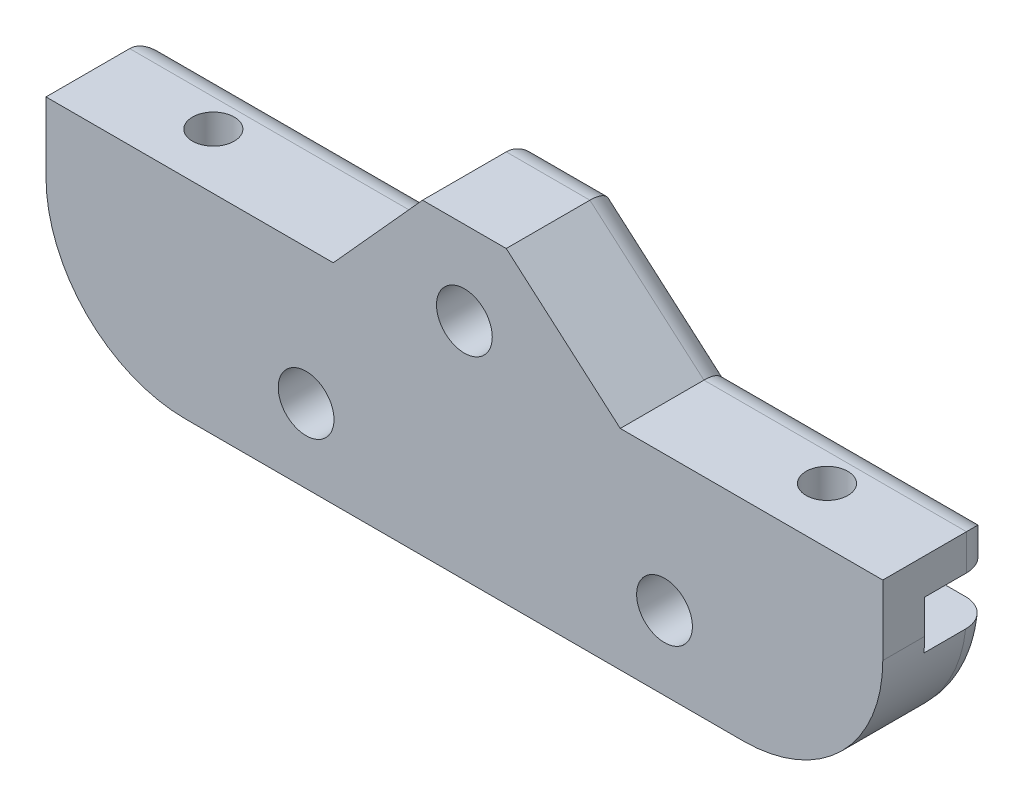
from build123d import *

# Parameters (mm, degrees)
BOSS_EXTRU_1_DEPTH             = 4
BOSS_EXTRU_1_DEPTH_BACK        = 4
ESQUISSE3_R                    = 2
ENL_V_MAT_EXTRU_1_DEPTH        = 5
ENL_V_MAT_EXTRU_1_DEPTH_BACK   = 5
BOSS_EXTRU_2_REACH             = 6
BOSS_EXTRU_2_DIRECTION_2_REACH = 6
ENL_V_START                    = -4
ESQUISSE4_W                    = 60
ESQUISSE4_H                    = 3.5
ENL_V_MAT_EXTRU_2_DEPTH        = 5
ENL_V_START_2                  = 9.713229
ESQUISSE7_R                    = 1.5
ENL_V_MAT_EXTRU_4_DEPTH        = 6.063229
CONG_1_R                       = 10
CONG_2_R                       = 2


with BuildPart() as part:
    # Esquisse1 → Boss.-Extru.1 (new body, two sides)
    with BuildSketch(Plane.XY) as boss_extru_1_sk:
        Polygon((-18.056919343, 0.131274222), (-15.479170984, -5.286770941), (18.771312817, -5.286770941), (21.159805355, 1.060426821), (3, 16.8), (-3, 16.8), align=None)
    extrude(amount=BOSS_EXTRU_1_DEPTH)
    extrude(boss_extru_1_sk.sketch, amount=-BOSS_EXTRU_1_DEPTH_BACK)

    # Esquisse3 → Enl_v. mat.-Extru.1 (cut, two sides)
    with BuildSketch(Plane.XY) as enl_v_mat_extru_1_sk:
        with Locations((0, 10.8)):
            Circle(ESQUISSE3_R)
        with Locations((-11.35, 0)):
            Circle(ESQUISSE3_R)
        with Locations((14.35, 0)):
            Circle(ESQUISSE3_R)
    extrude(amount=ENL_V_MAT_EXTRU_1_DEPTH, mode=Mode.SUBTRACT)
    extrude(enl_v_mat_extru_1_sk.sketch, amount=-ENL_V_MAT_EXTRU_1_DEPTH_BACK, mode=Mode.SUBTRACT)

    # Boss.-Extru.2: up to this face of the body (flat: up to its plane)
    boss_extru_2_end = Plane(part.part.faces().sort_by_distance((1.373128785, 3.366991502, 4))[0])
    # Esquisse6 → Boss.-Extru.2 (add, up to the picked face)
    with BuildSketch(Plane.XY, mode=Mode.PRIVATE) as boss_extru_2_sk1:
        Polygon((-9.401505424, 9.713229059), (-30, 9.713229059), (-30, -5.286770941), (-15.479170984, -5.286770941), (-18.056919343, 0.131274222), align=None)
    boss_extru_2_tool1 = split(extrude(boss_extru_2_sk1.sketch, amount=BOSS_EXTRU_2_REACH, mode=Mode.PRIVATE), bisect_by=boss_extru_2_end, keep=Keep.BOTH, mode=Mode.PRIVATE)
    add(boss_extru_2_tool1.solids().sort_by_distance((-22.205202, 2.823075, 0))[0])
    # Esquisse6 → Boss.-Extru.2 (add, up to the picked face)
    with BuildSketch(Plane.XY, mode=Mode.PRIVATE) as boss_extru_2_sk2:
        Polygon((18.771312817, -5.286770941), (30, -5.286770941), (30, 9.713229059), (11.176484802, 9.713229059), (21.159805355, 1.060426821), align=None)
    boss_extru_2_tool2 = split(extrude(boss_extru_2_sk2.sketch, amount=BOSS_EXTRU_2_REACH, mode=Mode.PRIVATE), bisect_by=boss_extru_2_end, keep=Keep.BOTH, mode=Mode.PRIVATE)
    add(boss_extru_2_tool2.solids().sort_by_distance((23.539357, 3.077844, 0))[0])

    # Boss.-Extru.2 direction 2: up to this face of the body (flat: up to its plane)
    boss_extru_2_direction_2_end = Plane(part.part.faces().sort_by_distance((1.373128785, 3.366991502, -4))[0])
    # Esquisse6 → Boss.-Extru.2 direction 2 (add, up to the picked face)
    with BuildSketch(Plane.XY, mode=Mode.PRIVATE) as boss_extru_2_direction_2_sk1:
        Polygon((-9.401505424, 9.713229059), (-30, 9.713229059), (-30, -5.286770941), (-15.479170984, -5.286770941), (-18.056919343, 0.131274222), align=None)
    boss_extru_2_direction_2_tool1 = split(extrude(boss_extru_2_direction_2_sk1.sketch, amount=-BOSS_EXTRU_2_DIRECTION_2_REACH, mode=Mode.PRIVATE), bisect_by=boss_extru_2_direction_2_end, keep=Keep.BOTH, mode=Mode.PRIVATE)
    add(boss_extru_2_direction_2_tool1.solids().sort_by_distance((-22.205202, 2.823075, 0))[0])
    # Esquisse6 → Boss.-Extru.2 direction 2 (add, up to the picked face)
    with BuildSketch(Plane.XY, mode=Mode.PRIVATE) as boss_extru_2_direction_2_sk2:
        Polygon((18.771312817, -5.286770941), (30, -5.286770941), (30, 9.713229059), (11.176484802, 9.713229059), (21.159805355, 1.060426821), align=None)
    boss_extru_2_direction_2_tool2 = split(extrude(boss_extru_2_direction_2_sk2.sketch, amount=-BOSS_EXTRU_2_DIRECTION_2_REACH, mode=Mode.PRIVATE), bisect_by=boss_extru_2_direction_2_end, keep=Keep.BOTH, mode=Mode.PRIVATE)
    add(boss_extru_2_direction_2_tool2.solids().sort_by_distance((23.539357, 3.077844, 0))[0])

    # Esquisse4 → Enl_v. mat.-Extru.2 (cut)
    with BuildSketch(Plane.XY.offset(ENL_V_START)):
        with Locations((0, 5.4)):
            Rectangle(ESQUISSE4_W, ESQUISSE4_H)
    extrude(amount=ENL_V_MAT_EXTRU_2_DEPTH, mode=Mode.SUBTRACT)

    # Esquisse7 → Enl_v. mat.-Extru.4 (cut)
    with BuildSketch(Plane(origin=(0, 0, 0), x_dir=(1, 0, 0), z_dir=(0, 1, 0)).offset(ENL_V_START_2)):
        with Locations((-22, 0)):
            Circle(ESQUISSE7_R)
        with Locations((22, 0)):
            Circle(ESQUISSE7_R)
    extrude(amount=-ENL_V_MAT_EXTRU_4_DEPTH, mode=Mode.SUBTRACT)

    # Cong_1
    cong_1_edges = [part.edges().sort_by_distance(p)[0] for p in [
        (30, -5.286770941, 0),
        (-30, -5.286770941, 0),
    ]]
    fillet(cong_1_edges, radius=CONG_1_R)

    # Cong_2
    cong_2_edges = [part.edges().sort_by_distance(p)[0] for p in [
        (0, -5.286770941, -4),
        (-26.684598321, -2.724253398, -4),
        (26.684598321, -2.724253398, -4),
        (0, 16.8, -4),
        (-6.200752712, 13.256614529, -4),
        (-19.700752712, 9.713229059, -4),
        (-30, 8.431614529, -4),
        (7.088242401, 13.256614529, -4),
        (20.588242401, 9.713229059, -4),
        (30, 8.431614529, -4),
    ]]
    fillet(cong_2_edges, radius=CONG_2_R)


solid = part.part
